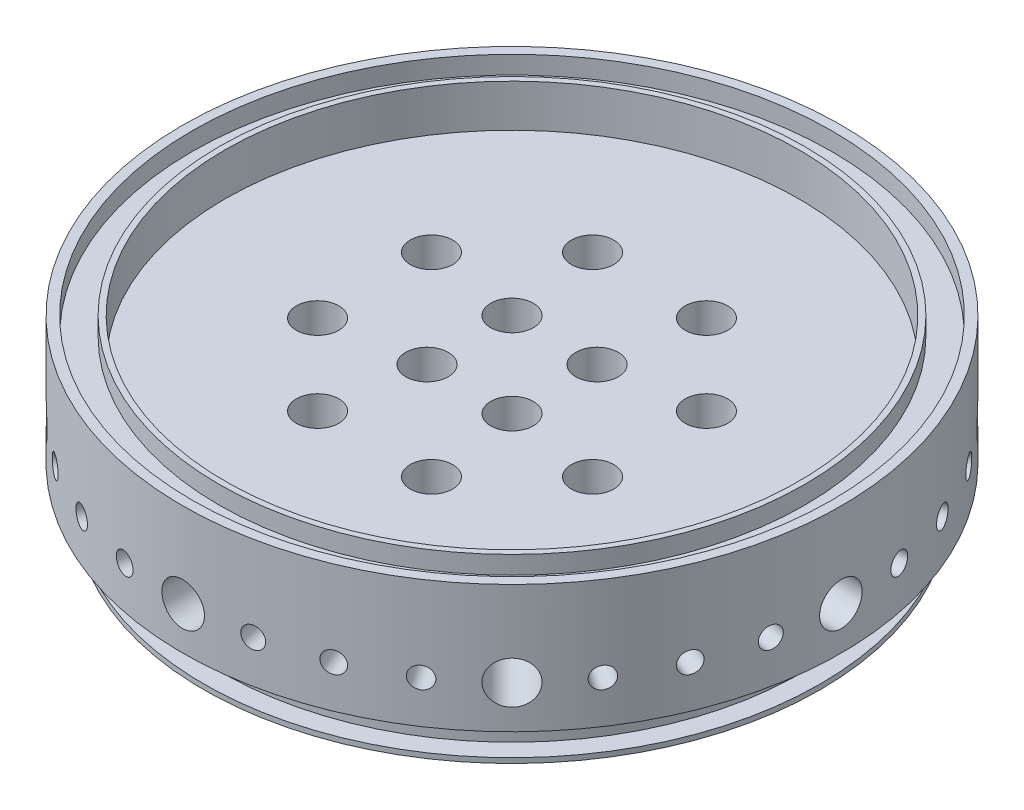
from build123d import *

# Parameters (mm, degrees)
CIRPATTERN9_COUNT  = 32
CIRPATTERN1_COUNT  = 8
CIRPATTERN2_COUNT  = 8
CIRPATTERN3_COUNT  = 4
CIRPATTERN4_COUNT  = 4
CIRPATTERN5_COUNT  = 8
CIRPATTERN6_COUNT  = 32
CIRPATTERN10_COUNT = 8
CIRPATTERN7_COUNT  = 4
CIRPATTERN8_COUNT  = 8


with BuildPart() as part:
    # Sketch1 → Revolve1 (revolve)
    with BuildSketch(Plane.XY):
        Polygon((0, 0), (-46.0375, 0), (-46.0375, 0.75565), (-43.2181, 0.75565), (-43.2181, 5.55625), (-46.0375, 5.55625), (-46.0375, 6.35), (-49.2125, 6.35), (-49.2125, 25.4), (-47.7774, 25.4), (-47.7774, 22.7076), (-43.7134, 22.7076), (-43.7134, 25.4), (-42.8625, 25.4), (-42.8625, 19.05), (0, 19.05), align=None)
    revolve(axis=Axis((0, 19.05, 0), (0, -1, 0)))

    # Sketch37 → 1_8 _0.125_ Diameter Hole2 (revolve, cut)
    with BuildSketch(Plane(origin=(49.2125, 12.7, 0), x_dir=(0, 0, -1), z_dir=(0, 1, 0))):
        Polygon((0, 0), (0, 13.653866233), (1.5875, 12.7), (1.5875, 0), align=None)
    f_1_8_0_125_diameter_hole2 = revolve(axis=Axis((55.5625, 12.7, 0), (-1, 0, 0)), mode=Mode.SUBTRACT)

    # CirPattern9: 1_8 _0.125_ Diameter Hole2 ×32 about axis
    cirpattern9_axis = Axis((0, -42.3, 0), (0, 1, 0))
    for i in range(1, CIRPATTERN9_COUNT):
        add(f_1_8_0_125_diameter_hole2.rotate(cirpattern9_axis, i * 360 / CIRPATTERN9_COUNT), mode=Mode.SUBTRACT)

    # Sketch13 → 1_4 _0.25_ Diameter Hole1 (revolve, cut)
    with BuildSketch(Plane(origin=(49.2125, 12.7, 0), x_dir=(0, 0, -1), z_dir=(0, 1, 0))):
        Polygon((0, 0), (0, 14.607732465), (3.175, 12.7), (3.175, 0), align=None)
    f_1_4_0_25_diameter_hole1 = revolve(axis=Axis((55.5625, 12.7, 0), (-1, 0, 0)), mode=Mode.SUBTRACT)

    # Sketch15 → 3_16 _0.1875_ Diameter Hole1 (revolve, cut)
    with BuildSketch(Plane(origin=(49.2125, 12.7, 0), x_dir=(0, 0, -1), z_dir=(0, 1, 0))):
        Polygon((0, 0), (0, 33.180799349), (2.38125, 31.75), (2.38125, 0), align=None)
    f_3_16_0_1875_diameter_hole1 = revolve(axis=Axis((55.5625, 12.7, 0), (-1, 0, 0)), mode=Mode.SUBTRACT)

    # Sketch17 → 1_8 _0.125_ Diameter Hole1 (revolve, cut)
    with BuildSketch(Plane(origin=(49.2125, 12.7, 0), x_dir=(0, 0, -1), z_dir=(0, 1, 0))):
        Polygon((0, 0), (0, 45.403866233), (1.5875, 44.45), (1.5875, 0), align=None)
    f_1_8_0_125_diameter_hole1 = revolve(axis=Axis((55.5625, 12.7, 0), (-1, 0, 0)), mode=Mode.SUBTRACT)

    # CirPattern1: 1_4 _0.25_ Diameter Hole1 ×8 about axis
    cirpattern1_axis = Axis((0, -42.3, 0), (0, 1, 0))
    for i in range(1, CIRPATTERN1_COUNT):
        add(f_1_4_0_25_diameter_hole1.rotate(cirpattern1_axis, i * 360 / CIRPATTERN1_COUNT), mode=Mode.SUBTRACT)

    # CirPattern2: 3_16 _0.1875_ Diameter Hole1 ×8 about axis
    cirpattern2_axis = Axis((0, -42.3, 0), (0, 1, 0))
    for i in range(1, CIRPATTERN2_COUNT):
        add(f_3_16_0_1875_diameter_hole1.rotate(cirpattern2_axis, i * 360 / CIRPATTERN2_COUNT), mode=Mode.SUBTRACT)

    # CirPattern3: 1_8 _0.125_ Diameter Hole1 ×4 about axis
    cirpattern3_axis = Axis((0, -42.3, 0), (0, 1, 0))
    for i in range(1, CIRPATTERN3_COUNT):
        add(f_1_8_0_125_diameter_hole1.rotate(cirpattern3_axis, i * 360 / CIRPATTERN3_COUNT), mode=Mode.SUBTRACT)

    # Sketch20 → inner large LOX holes (revolve, cut)
    with BuildSketch(Plane(origin=(-6.35, 19.05, 6.35), x_dir=(0, 0, 1), z_dir=(1, 0, 0))):
        Polygon((0, 0), (0, 14.607732465), (3.175, 12.7), (3.175, 0), align=None)
    inner_large_lox_holes = revolve(axis=Axis((-6.35, 25.4, 6.35), (0, -1, 0)), mode=Mode.SUBTRACT)

    # Sketch22 → outer large LOX hole (revolve, cut)
    with BuildSketch(Plane(origin=(-20.53322261, 19.05, 8.505139284), x_dir=(0, 0, 1), z_dir=(1, 0, 0))):
        Polygon((0, 0), (0, 14.607732465), (3.175, 12.7), (3.175, 0), align=None)
    outer_large_lox_hole = revolve(axis=Axis((-20.53322261, 25.4, 8.505139284), (0, -1, 0)), mode=Mode.SUBTRACT)

    # CirPattern4: inner large LOX holes ×4 about axis
    cirpattern4_axis = Axis((0, 0, 0), (0, 1, 0))
    for i in range(1, CIRPATTERN4_COUNT):
        add(inner_large_lox_holes.rotate(cirpattern4_axis, i * 360 / CIRPATTERN4_COUNT), mode=Mode.SUBTRACT)

    # CirPattern5: outer large LOX hole ×8 about axis
    cirpattern5_axis = Axis((0, 0, 0), (0, 1, 0))
    for i in range(1, CIRPATTERN5_COUNT):
        add(outer_large_lox_hole.rotate(cirpattern5_axis, i * 360 / CIRPATTERN5_COUNT), mode=Mode.SUBTRACT)

    # Sketch26 → film cooling holes (revolve, cut)
    with BuildSketch(Plane(origin=(-41.817956978, -1.491762035, 0), x_dir=(0.939692621, -0.342020143, 0), z_dir=(0, 0, 1))):
        Polygon((0, 0), (0, 12.871695922), (0.28575, 12.7), (0.28575, 0), align=None)
    film_cooling_holes = revolve(axis=Axis((-43.989784888, -7.458810177, 0), (0.342020143, 0.939692621, 0)), mode=Mode.SUBTRACT)

    # CirPattern6: film cooling holes ×32 about axis
    cirpattern6_axis = Axis((0, -42.3, 0), (0, 1, 0))
    for i in range(1, CIRPATTERN6_COUNT):
        add(film_cooling_holes.rotate(cirpattern6_axis, i * 360 / CIRPATTERN6_COUNT), mode=Mode.SUBTRACT)

    # Sketch39 → 3_64 _0.04688_ Diameter Hole1 (revolve, cut)
    with BuildSketch(Plane(origin=(-41.817956978, -1.491762035, 0), x_dir=(0.939692621, -0.342020143, 0), z_dir=(0, 0, 1))):
        Polygon((0, 0), (0, 13.057737992), (0.595376, 12.7), (0.595376, 0), align=None)
    f_3_64_0_04688_diameter_hole1 = revolve(axis=Axis((-43.989784888, -7.458810177, 0), (0.342020143, 0.939692621, 0)), mode=Mode.SUBTRACT)

    # CirPattern10: 3_64 _0.04688_ Diameter Hole1 ×8 about axis
    cirpattern10_axis = Axis((0, -42.3, 0), (0, 1, 0))
    for i in range(1, CIRPATTERN10_COUNT):
        add(f_3_64_0_04688_diameter_hole1.rotate(cirpattern10_axis, i * 360 / CIRPATTERN10_COUNT), mode=Mode.SUBTRACT)

    # Sketch28 → 1_16 _0.0625_ Diameter Hole2 (revolve, cut)
    with BuildSketch(Plane(origin=(-6.35, 0, 0), x_dir=(0, 0, -1), z_dir=(1, 0, 0))):
        Polygon((0, 0), (0, 13.176933116), (0.79375, 12.7), (0.79375, 0), align=None)
    f_1_16_0_0625_diameter_hole2 = revolve(axis=Axis((-6.35, -6.35, 0), (0, 1, 0)), mode=Mode.SUBTRACT)

    # Sketch30 → 1_16 _0.0625_ Diameter Hole1 (revolve, cut)
    with BuildSketch(Plane(origin=(-6.35, -6.35, 0), x_dir=(0, 0.5, -0.866025404), z_dir=(1, 0, 0))):
        Polygon((0, 0), (0, 16.097933116), (0.79375, 15.621), (0.79375, 0), align=None)
    f_1_16_0_0625_diameter_hole1 = revolve(axis=Axis((-6.35, -11.849261314, -3.175), (0, 0.866025404, 0.5)), mode=Mode.SUBTRACT)

    # Sketch33 → 1_16 _0.0625_ Diameter Hole3 (revolve, cut)
    with BuildSketch(Plane(origin=(-22.225, 0, 0), x_dir=(0, 0, -1), z_dir=(1, 0, 0))):
        Polygon((0, 0), (0, 13.176933116), (0.79375, 12.7), (0.79375, 0), align=None)
    f_1_16_0_0625_diameter_hole3 = revolve(axis=Axis((-22.225, -6.35, 0), (0, 1, 0)), mode=Mode.SUBTRACT)

    # Sketch35 → 1_16 _0.0625_ Diameter Hole4 (revolve, cut)
    with BuildSketch(Plane(origin=(-22.225, -6.35, 0), x_dir=(0, 0.5, -0.866025404), z_dir=(1, 0, 0))):
        Polygon((0, 0), (0, 19.526933116), (0.79375, 19.05), (0.79375, 0), align=None)
    f_1_16_0_0625_diameter_hole4 = revolve(axis=Axis((-22.225, -11.849261314, -3.175), (0, 0.866025404, 0.5)), mode=Mode.SUBTRACT)

    # Mirror1: 1_16 _0.0625_ Diameter Hole1 across plane
    add(f_1_16_0_0625_diameter_hole1.mirror(Plane.XY), mode=Mode.SUBTRACT)

    # Mirror2: 1_16 _0.0625_ Diameter Hole4 across plane
    add(f_1_16_0_0625_diameter_hole4.mirror(Plane.XY), mode=Mode.SUBTRACT)

    # CirPattern7: 1_16 _0.0625_ Diameter Hole1, 1_16 _0.0625_ Diameter Hole2 ×4 about axis
    cirpattern7_axis = Axis((0, 0, 0), (0, 1, 0))
    for i in range(1, CIRPATTERN7_COUNT):
        add(f_1_16_0_0625_diameter_hole1.rotate(cirpattern7_axis, i * 360 / CIRPATTERN7_COUNT), mode=Mode.SUBTRACT)
        add(f_1_16_0_0625_diameter_hole2.rotate(cirpattern7_axis, i * 360 / CIRPATTERN7_COUNT), mode=Mode.SUBTRACT)

    # CirPattern7 copy 1 sketch → CirPattern7 copy 1 (revolve, cut)
    with BuildSketch(Plane(origin=(0, -6.35, 6.35), x_dir=(0.866025404, 0.5, 0), z_dir=(0, 0, -1))):
        Polygon((0, 0), (0, -16.097933116), (0.79375, -15.621), (0.79375, 0), align=None)
    revolve(axis=Axis((3.175, -11.849261314, 6.35), (0.5, -0.866025404, 0)), mode=Mode.SUBTRACT)

    # CirPattern7 copy 2 sketch → CirPattern7 copy 2 (revolve, cut)
    with BuildSketch(Plane(origin=(6.35, -6.35, 0), x_dir=(0, 0.5, -0.866025404), z_dir=(-1, 0, 0))):
        Polygon((0, 0), (0, -16.097933116), (0.79375, -15.621), (0.79375, 0), align=None)
    revolve(axis=Axis((6.35, -11.849261314, -3.175), (0, -0.866025404, -0.5)), mode=Mode.SUBTRACT)

    # CirPattern7 copy 3 sketch → CirPattern7 copy 3 (revolve, cut)
    with BuildSketch(Plane(origin=(0, -6.35, -6.35), x_dir=(-0.866025404, 0.5, 0), z_dir=(0, 0, 1))):
        Polygon((0, 0), (0, -16.097933116), (0.79375, -15.621), (0.79375, 0), align=None)
    revolve(axis=Axis((-3.175, -11.849261314, -6.35), (-0.5, -0.866025404, 0)), mode=Mode.SUBTRACT)

    # CirPattern8: 1_16 _0.0625_ Diameter Hole4, 1_16 _0.0625_ Diameter Hole3 ×8 about axis
    cirpattern8_axis = Axis((0, 0, 0), (0, 1, 0))
    for i in range(1, CIRPATTERN8_COUNT):
        add(f_1_16_0_0625_diameter_hole4.rotate(cirpattern8_axis, i * 360 / CIRPATTERN8_COUNT), mode=Mode.SUBTRACT)
        add(f_1_16_0_0625_diameter_hole3.rotate(cirpattern8_axis, i * 360 / CIRPATTERN8_COUNT), mode=Mode.SUBTRACT)

    # CirPattern8 copy 1 sketch → CirPattern8 copy 1 (revolve, cut)
    with BuildSketch(Plane(origin=(-15.715448212, -6.35, 15.715448212), x_dir=(0.612372436, 0.5, 0.612372436), z_dir=(0.707106781, 0, -0.707106781))):
        Polygon((0, 0), (0, -19.526933116), (0.79375, -19.05), (0.79375, 0), align=None)
    revolve(axis=Axis((-13.470384182, -11.849261314, 17.960512242), (0.353553391, -0.866025404, 0.353553391)), mode=Mode.SUBTRACT)

    # CirPattern8 copy 2 sketch → CirPattern8 copy 2 (revolve, cut)
    with BuildSketch(Plane(origin=(0, -6.35, 22.225), x_dir=(0.866025404, 0.5, 0), z_dir=(0, 0, -1))):
        Polygon((0, 0), (0, -19.526933116), (0.79375, -19.05), (0.79375, 0), align=None)
    revolve(axis=Axis((3.175, -11.849261314, 22.225), (0.5, -0.866025404, 0)), mode=Mode.SUBTRACT)

    # CirPattern8 copy 3 sketch → CirPattern8 copy 3 (revolve, cut)
    with BuildSketch(Plane(origin=(15.715448212, -6.35, 15.715448212), x_dir=(0.612372436, 0.5, -0.612372436), z_dir=(-0.707106781, 0, -0.707106781))):
        Polygon((0, 0), (0, -19.526933116), (0.79375, -19.05), (0.79375, 0), align=None)
    revolve(axis=Axis((17.960512242, -11.849261314, 13.470384182), (0.353553391, -0.866025404, -0.353553391)), mode=Mode.SUBTRACT)

    # CirPattern8 copy 4 sketch → CirPattern8 copy 4 (revolve, cut)
    with BuildSketch(Plane(origin=(22.225, -6.35, 0), x_dir=(0, 0.5, -0.866025404), z_dir=(-1, 0, 0))):
        Polygon((0, 0), (0, -19.526933116), (0.79375, -19.05), (0.79375, 0), align=None)
    revolve(axis=Axis((22.225, -11.849261314, -3.175), (0, -0.866025404, -0.5)), mode=Mode.SUBTRACT)

    # CirPattern8 copy 5 sketch → CirPattern8 copy 5 (revolve, cut)
    with BuildSketch(Plane(origin=(15.715448212, -6.35, -15.715448212), x_dir=(-0.612372436, 0.5, -0.612372436), z_dir=(-0.707106781, 0, 0.707106781))):
        Polygon((0, 0), (0, -19.526933116), (0.79375, -19.05), (0.79375, 0), align=None)
    revolve(axis=Axis((13.470384182, -11.849261314, -17.960512242), (-0.353553391, -0.866025404, -0.353553391)), mode=Mode.SUBTRACT)

    # CirPattern8 copy 6 sketch → CirPattern8 copy 6 (revolve, cut)
    with BuildSketch(Plane(origin=(0, -6.35, -22.225), x_dir=(-0.866025404, 0.5, 0), z_dir=(0, 0, 1))):
        Polygon((0, 0), (0, -19.526933116), (0.79375, -19.05), (0.79375, 0), align=None)
    revolve(axis=Axis((-3.175, -11.849261314, -22.225), (-0.5, -0.866025404, 0)), mode=Mode.SUBTRACT)

    # CirPattern8 copy 7 sketch → CirPattern8 copy 7 (revolve, cut)
    with BuildSketch(Plane(origin=(-15.715448212, -6.35, -15.715448212), x_dir=(-0.612372436, 0.5, 0.612372436), z_dir=(0.707106781, 0, 0.707106781))):
        Polygon((0, 0), (0, -19.526933116), (0.79375, -19.05), (0.79375, 0), align=None)
    revolve(axis=Axis((-17.960512242, -11.849261314, -13.470384182), (-0.353553391, -0.866025404, 0.353553391)), mode=Mode.SUBTRACT)


solid = part.part
